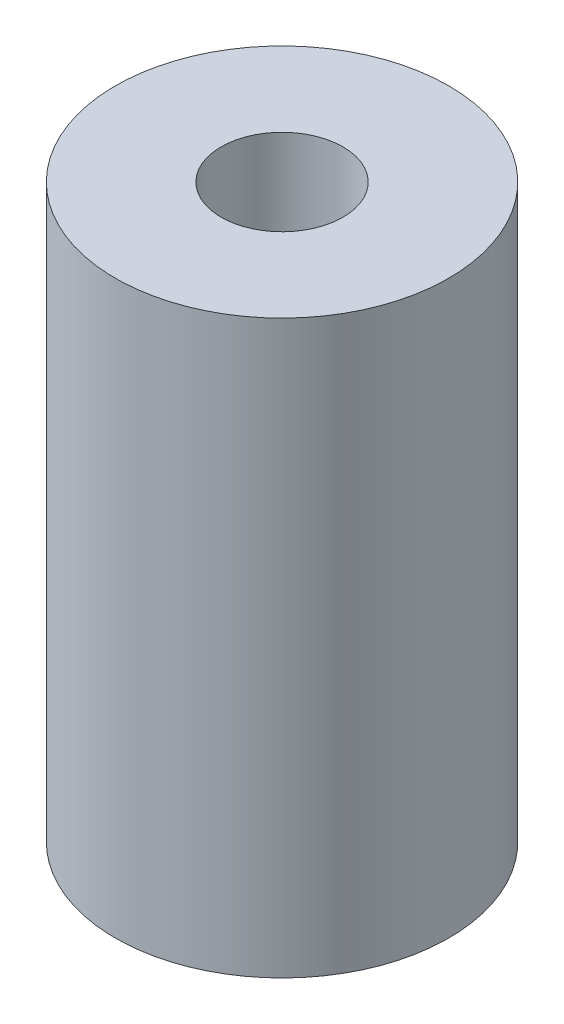
from build123d import *

# Parameters (mm, degrees)
SKETCH2_W = 7.0485
SKETCH2_H = 38.1


with BuildPart() as part:
    # Sketch2 → Revolve1 (revolve)
    with BuildSketch(Plane.XY):
        with Locations((7.58825, 19.05)):
            Rectangle(SKETCH2_W, SKETCH2_H)
    revolve(axis=Axis((0, 0, 0), (0, 1, 0)))


solid = part.part
